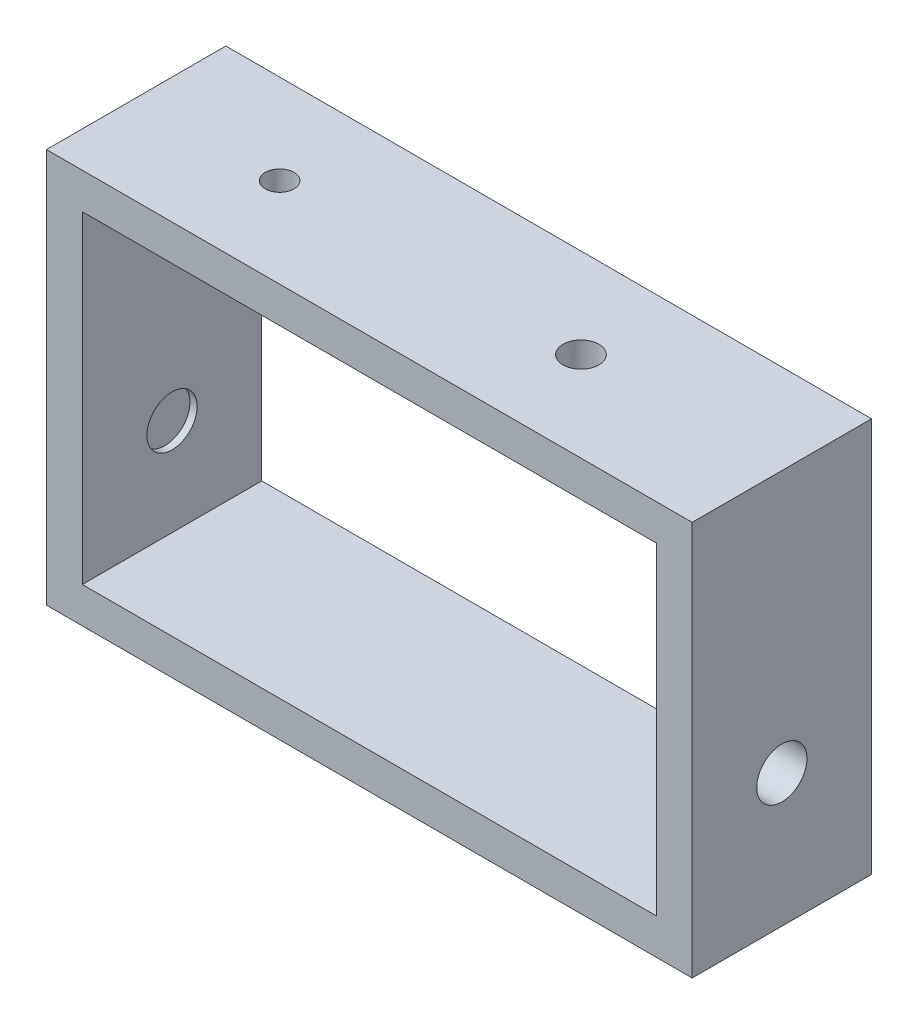
from build123d import *

# Parameters (mm, degrees)
CROQUIS2_W              = 90
CROQUIS2_H              = 55
CROQUIS2_W_2            = 80
CROQUIS2_H_2            = 45
SALIENTE_EXTRUIR2_DEPTH = 12.5
CROQUIS4_R              = 3.5
CORTAR_EXTRUIR2_DEPTH   = 86
CROQUIS5_R              = 2
CROQUIS5_R_2            = 2.5
CORTAR_EXTRUIR4_DEPTH   = 10


with BuildPart() as part:
    # Croquis2 → Saliente-Extruir2 (new body, symmetric)
    with BuildSketch(Plane.XY):
        with Locations((45, 27.5)):
            Rectangle(CROQUIS2_W, CROQUIS2_H)
        with Locations((45, 27.5)):
            Rectangle(CROQUIS2_W_2, CROQUIS2_H_2, mode=Mode.SUBTRACT)
    extrude(amount=SALIENTE_EXTRUIR2_DEPTH, both=True)

    # Croquis4 → Cortar-Extruir2 (cut)
    with BuildSketch(Plane(origin=(90, 0, 0), x_dir=(0, 0, -1), z_dir=(1, 0, 0))):
        with Locations((0, 18.5)):
            Circle(CROQUIS4_R)
    extrude(amount=-CORTAR_EXTRUIR2_DEPTH, mode=Mode.SUBTRACT)

    # Croquis5 → Cortar-Extruir4 (cut)
    with BuildSketch(Plane(origin=(0, 55, 0), x_dir=(1, 0, 0), z_dir=(0, 1, 0))):
        with Locations((20, 0)):
            Circle(CROQUIS5_R)
        with Locations((62, 0)):
            Circle(CROQUIS5_R_2)
    extrude(amount=-CORTAR_EXTRUIR4_DEPTH, mode=Mode.SUBTRACT)


solid = part.part
